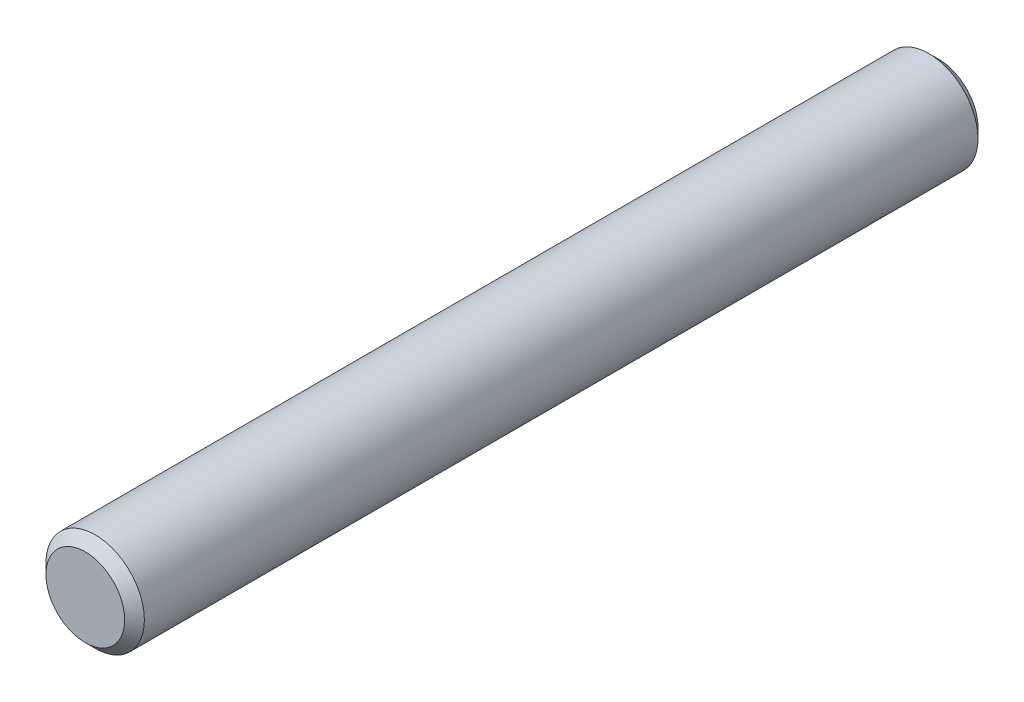
from build123d import *

# Parameters (mm, degrees)
SKETCH1_R           = 1.5
BOSS_EXTRUDE1_DEPTH = 13
CHAMFER1_SIZE       = 0.3


with BuildPart() as part:
    # Sketch1 → Boss-Extrude1 (new body, symmetric)
    with BuildSketch(Plane.XY):
        Circle(SKETCH1_R)
    extrude(amount=BOSS_EXTRUDE1_DEPTH, both=True)

    # Chamfer1
    chamfer1_edges = [part.edges().sort_by_distance(p)[0] for p in [
        (-1.5, 0, -13),
        (-1.5, 0, 13),
    ]]
    chamfer(chamfer1_edges, length=CHAMFER1_SIZE)


solid = part.part
